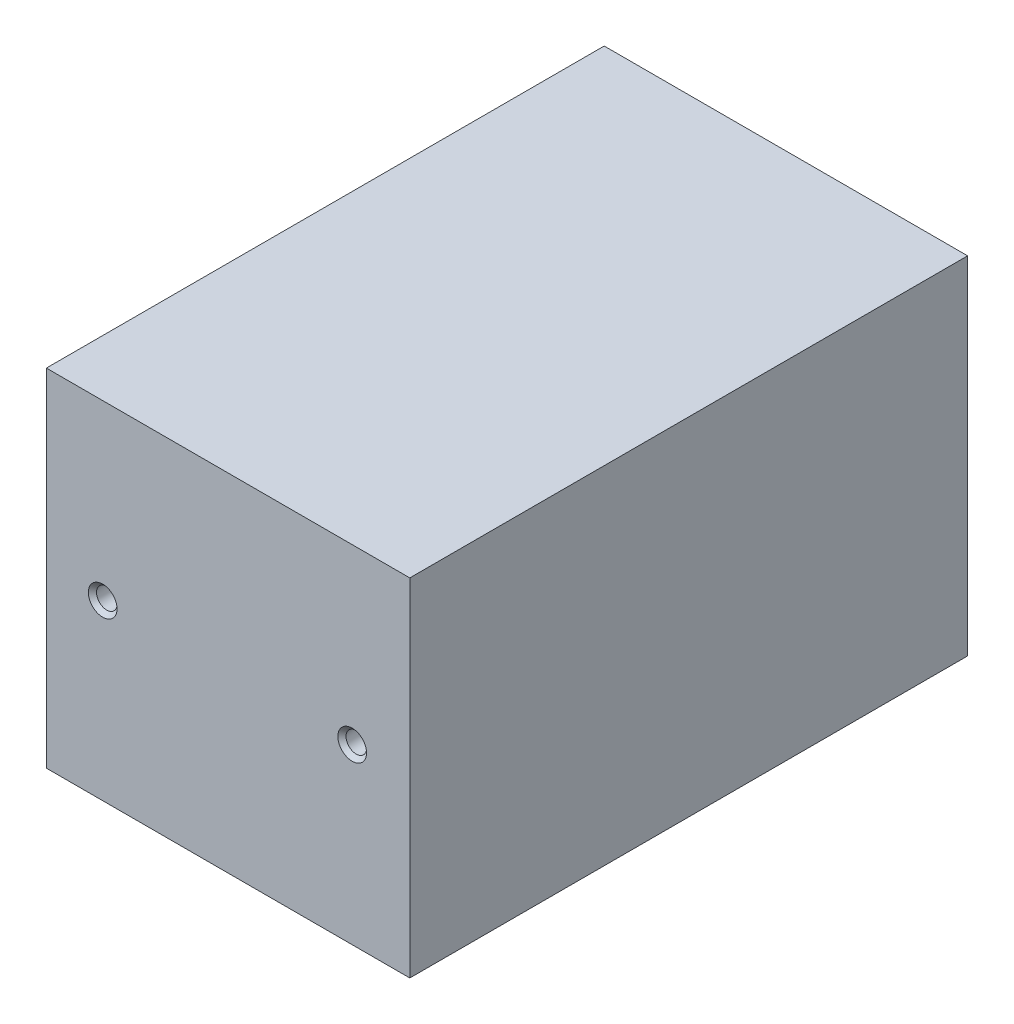
from build123d import *

# Parameters (mm, degrees)
SKETCH4_W                       = 88.626489964
SKETCH4_H                       = 130.535595586
BOSS_EXTRUDE3_DEPTH             = 42.25
SHELL1_T                        = 1
SKETCH5_W                       = 88.626489964
SKETCH5_H                       = 84.5
BOSS_EXTRUDE4_DEPTH             = 5.5
M6X1_0_TAPPED_HOLE1_D           = 5
M6X1_0_TAPPED_HOLE1_DEPTH       = 6.5
M6X1_0_TAPPED_HOLE1_CSINK_D     = 7
M6X1_0_TAPPED_HOLE1_CSINK_ANGLE = 90


with BuildPart() as part:
    # Sketch4 → Boss-Extrude3 (new body, symmetric)
    with BuildSketch(Plane(origin=(0, 0, 0), x_dir=(1, 0, 0), z_dir=(0, 1, 0))):
        Rectangle(SKETCH4_W, SKETCH4_H)
    extrude(amount=BOSS_EXTRUDE3_DEPTH, both=True)

    # Shell1 (no face opened: a closed hollow body)
    add(offset(amount=-SHELL1_T, mode=Mode.PRIVATE), mode=Mode.SUBTRACT)

    # Sketch5 → Boss-Extrude4 (add)
    with BuildSketch(Plane.XY.offset(65.267797793)):
        Rectangle(SKETCH5_W, SKETCH5_H)
    extrude(amount=BOSS_EXTRUDE4_DEPTH)

    # M6x1.0 Tapped Hole1
    with Locations(Plane.XY.offset(70.767797793)):
        with Locations((30.265999315, 0), (-30.578112918, 0)):
            CounterSinkHole(M6X1_0_TAPPED_HOLE1_D / 2, M6X1_0_TAPPED_HOLE1_CSINK_D / 2, depth=M6X1_0_TAPPED_HOLE1_DEPTH, counter_sink_angle=M6X1_0_TAPPED_HOLE1_CSINK_ANGLE)


solid = part.part
